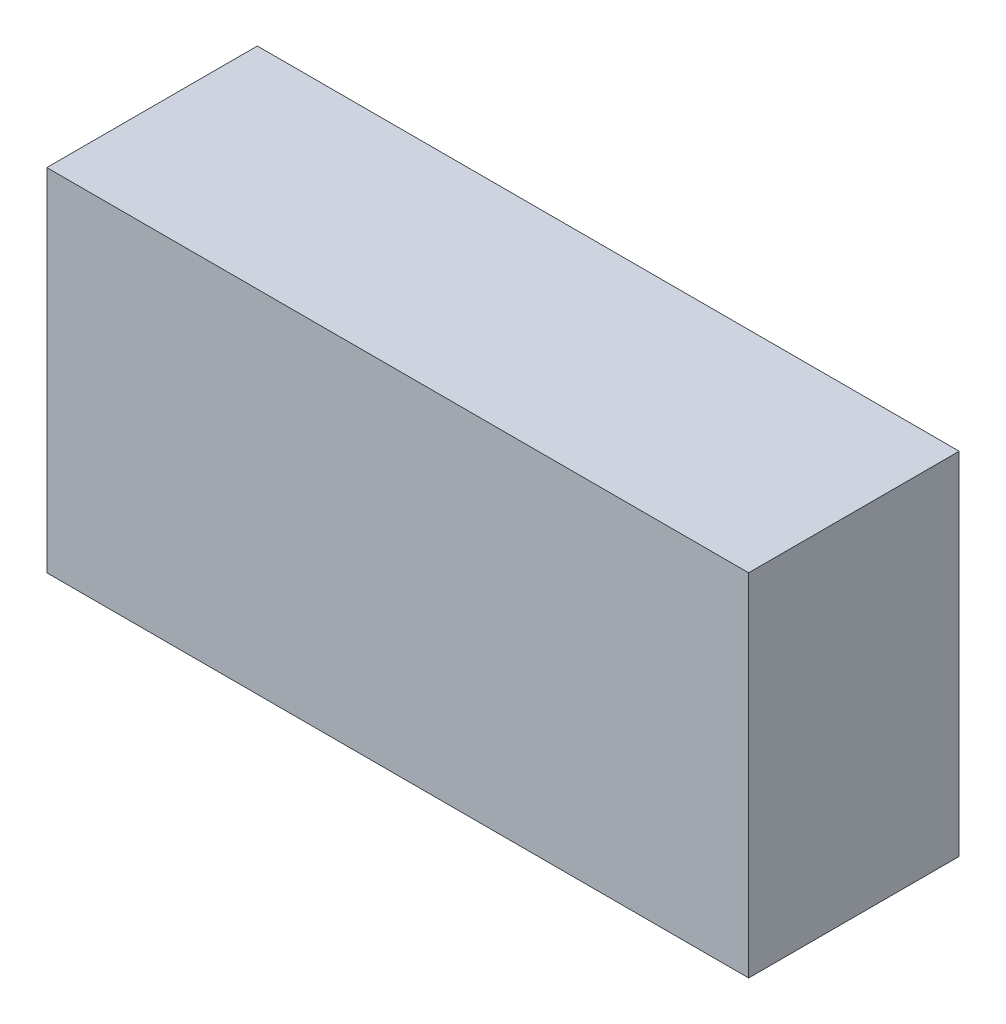
from build123d import *

# Parameters (mm, degrees)
SKETCH1_W           = 80
SKETCH1_H           = 40
BOSS_EXTRUDE1_DEPTH = 24


with BuildPart() as part:
    # Sketch1 → Boss-Extrude1 (new body)
    with BuildSketch(Plane.XY):
        with Locations((40, -20)):
            Rectangle(SKETCH1_W, SKETCH1_H)
    extrude(amount=BOSS_EXTRUDE1_DEPTH)


solid = part.part
